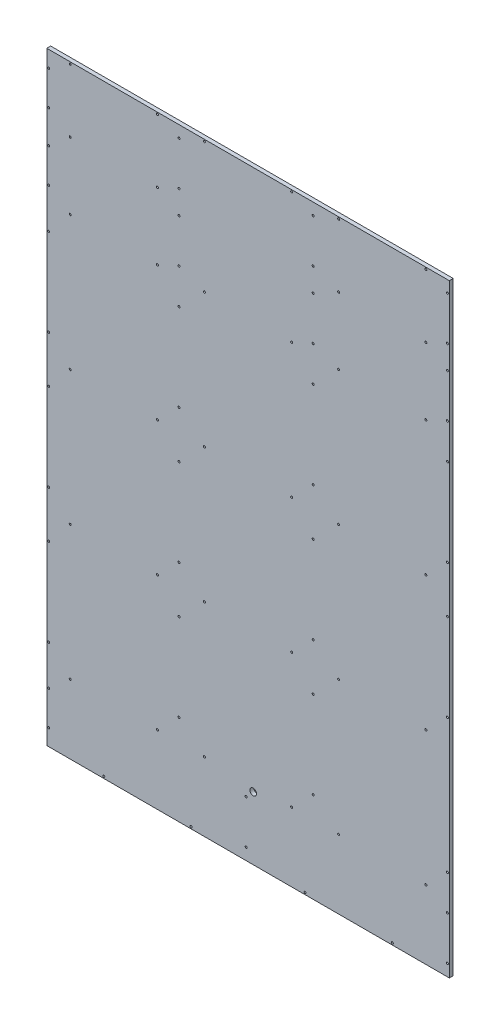
from build123d import *

# Parameters (mm, degrees)
SKETCH1_W           = 600
SKETCH1_H           = 900
SKETCH1_R           = 1.5
BOSS_EXTRUDE1_DEPTH = 5.8
SKETCH2_R           = 1.5
BOSS_EXTRUDE3_DEPTH = 5.8
SKETCH3_R           = 5
CUT_EXTRUDE1_DEPTH  = 10


with BuildPart() as part:
    # Sketch1 → Boss-Extrude1 (new body)
    with BuildSketch(Plane.XY):
        with Locations((300, 450)):
            Rectangle(SKETCH1_W, SKETCH1_H)
        with Locations((165, 102.9)):
            Circle(SKETCH1_R, mode=Mode.SUBTRACT)
        with Locations((35, 102.9)):
            Circle(SKETCH1_R, mode=Mode.SUBTRACT)
        with Locations((197.1, 265)):
            Circle(SKETCH1_R, mode=Mode.SUBTRACT)
        with Locations((197.1, 135)):
            Circle(SKETCH1_R, mode=Mode.SUBTRACT)
        with Locations((2.9, 135)):
            Circle(SKETCH1_R, mode=Mode.SUBTRACT)
        with Locations((2.9, 265)):
            Circle(SKETCH1_R, mode=Mode.SUBTRACT)
        with Locations((10.9, 265)):
            Circle(SKETCH1_R, mode=Mode.SUBTRACT)
        with Locations((10.9, 135)):
            Circle(SKETCH1_R, mode=Mode.SUBTRACT)
        with Locations((85, 2.9)):
            Circle(SKETCH1_R, mode=Mode.SUBTRACT)
        with Locations((215, 2.9)):
            Circle(SKETCH1_R, mode=Mode.SUBTRACT)
        with Locations((297.1, 82.5)):
            Circle(SKETCH1_R, mode=Mode.SUBTRACT)
        with Locations((297.1, 17.5)):
            Circle(SKETCH1_R, mode=Mode.SUBTRACT)
        with Locations((2.9, 24.5)):
            Circle(SKETCH1_R, mode=Mode.SUBTRACT)
        with Locations((2.9, 75.5)):
            Circle(SKETCH1_R, mode=Mode.SUBTRACT)
        with Locations((10.9, 75.5)):
            Circle(SKETCH1_R, mode=Mode.SUBTRACT)
        with Locations((10.9, 24.5)):
            Circle(SKETCH1_R, mode=Mode.SUBTRACT)
        with Locations((35, 702.9)):
            Circle(SKETCH1_R, mode=Mode.SUBTRACT)
        with Locations((165, 702.9)):
            Circle(SKETCH1_R, mode=Mode.SUBTRACT)
        with Locations((197.1, 782.5)):
            Circle(SKETCH1_R, mode=Mode.SUBTRACT)
        with Locations((197.1, 717.5)):
            Circle(SKETCH1_R, mode=Mode.SUBTRACT)
        with Locations((2.9, 775.5)):
            Circle(SKETCH1_R, mode=Mode.SUBTRACT)
        with Locations((10.9, 775.5)):
            Circle(SKETCH1_R, mode=Mode.SUBTRACT)
        with Locations((2.9, 724.5)):
            Circle(SKETCH1_R, mode=Mode.SUBTRACT)
        with Locations((10.9, 724.5)):
            Circle(SKETCH1_R, mode=Mode.SUBTRACT)
        with Locations((385, 2.9)):
            Circle(SKETCH1_R, mode=Mode.SUBTRACT)
        with Locations((515, 2.9)):
            Circle(SKETCH1_R, mode=Mode.SUBTRACT)
        with Locations((597.1, 82.5)):
            Circle(SKETCH1_R, mode=Mode.SUBTRACT)
        with Locations((597.1, 17.5)):
            Circle(SKETCH1_R, mode=Mode.SUBTRACT)
        with Locations((302.9, 24.5)):
            Circle(SKETCH1_R, mode=Mode.SUBTRACT)
        with Locations((302.9, 75.5)):
            Circle(SKETCH1_R, mode=Mode.SUBTRACT)
        with Locations((310.9, 75.5)):
            Circle(SKETCH1_R, mode=Mode.SUBTRACT)
        with Locations((310.9, 24.5)):
            Circle(SKETCH1_R, mode=Mode.SUBTRACT)
        with Locations((365, 102.9)):
            Circle(SKETCH1_R, mode=Mode.SUBTRACT)
        with Locations((235, 102.9)):
            Circle(SKETCH1_R, mode=Mode.SUBTRACT)
        with Locations((397.1, 265)):
            Circle(SKETCH1_R, mode=Mode.SUBTRACT)
        with Locations((397.1, 135)):
            Circle(SKETCH1_R, mode=Mode.SUBTRACT)
        with Locations((202.9, 135)):
            Circle(SKETCH1_R, mode=Mode.SUBTRACT)
        with Locations((202.9, 265)):
            Circle(SKETCH1_R, mode=Mode.SUBTRACT)
        with Locations((210.9, 265)):
            Circle(SKETCH1_R, mode=Mode.SUBTRACT)
        with Locations((210.9, 135)):
            Circle(SKETCH1_R, mode=Mode.SUBTRACT)
        with Locations((565, 102.9)):
            Circle(SKETCH1_R, mode=Mode.SUBTRACT)
        with Locations((435, 102.9)):
            Circle(SKETCH1_R, mode=Mode.SUBTRACT)
        with Locations((597.1, 265)):
            Circle(SKETCH1_R, mode=Mode.SUBTRACT)
        with Locations((597.1, 135)):
            Circle(SKETCH1_R, mode=Mode.SUBTRACT)
        with Locations((402.9, 135)):
            Circle(SKETCH1_R, mode=Mode.SUBTRACT)
        with Locations((402.9, 265)):
            Circle(SKETCH1_R, mode=Mode.SUBTRACT)
        with Locations((410.9, 265)):
            Circle(SKETCH1_R, mode=Mode.SUBTRACT)
        with Locations((410.9, 135)):
            Circle(SKETCH1_R, mode=Mode.SUBTRACT)
        with Locations((365, 302.9)):
            Circle(SKETCH1_R, mode=Mode.SUBTRACT)
        with Locations((235, 302.9)):
            Circle(SKETCH1_R, mode=Mode.SUBTRACT)
        with Locations((397.1, 465)):
            Circle(SKETCH1_R, mode=Mode.SUBTRACT)
        with Locations((397.1, 335)):
            Circle(SKETCH1_R, mode=Mode.SUBTRACT)
        with Locations((202.9, 335)):
            Circle(SKETCH1_R, mode=Mode.SUBTRACT)
        with Locations((202.9, 465)):
            Circle(SKETCH1_R, mode=Mode.SUBTRACT)
        with Locations((210.9, 465)):
            Circle(SKETCH1_R, mode=Mode.SUBTRACT)
        with Locations((210.9, 335)):
            Circle(SKETCH1_R, mode=Mode.SUBTRACT)
        with Locations((565, 302.9)):
            Circle(SKETCH1_R, mode=Mode.SUBTRACT)
        with Locations((435, 302.9)):
            Circle(SKETCH1_R, mode=Mode.SUBTRACT)
        with Locations((597.1, 465)):
            Circle(SKETCH1_R, mode=Mode.SUBTRACT)
        with Locations((597.1, 335)):
            Circle(SKETCH1_R, mode=Mode.SUBTRACT)
        with Locations((402.9, 335)):
            Circle(SKETCH1_R, mode=Mode.SUBTRACT)
        with Locations((402.9, 465)):
            Circle(SKETCH1_R, mode=Mode.SUBTRACT)
        with Locations((410.9, 465)):
            Circle(SKETCH1_R, mode=Mode.SUBTRACT)
        with Locations((410.9, 335)):
            Circle(SKETCH1_R, mode=Mode.SUBTRACT)
        with Locations((365, 502.9)):
            Circle(SKETCH1_R, mode=Mode.SUBTRACT)
        with Locations((235, 502.9)):
            Circle(SKETCH1_R, mode=Mode.SUBTRACT)
        with Locations((397.1, 665)):
            Circle(SKETCH1_R, mode=Mode.SUBTRACT)
        with Locations((397.1, 535)):
            Circle(SKETCH1_R, mode=Mode.SUBTRACT)
        with Locations((202.9, 535)):
            Circle(SKETCH1_R, mode=Mode.SUBTRACT)
        with Locations((202.9, 665)):
            Circle(SKETCH1_R, mode=Mode.SUBTRACT)
        with Locations((210.9, 665)):
            Circle(SKETCH1_R, mode=Mode.SUBTRACT)
        with Locations((210.9, 535)):
            Circle(SKETCH1_R, mode=Mode.SUBTRACT)
        with Locations((565, 502.9)):
            Circle(SKETCH1_R, mode=Mode.SUBTRACT)
        with Locations((435, 502.9)):
            Circle(SKETCH1_R, mode=Mode.SUBTRACT)
        with Locations((597.1, 665)):
            Circle(SKETCH1_R, mode=Mode.SUBTRACT)
        with Locations((597.1, 535)):
            Circle(SKETCH1_R, mode=Mode.SUBTRACT)
        with Locations((402.9, 535)):
            Circle(SKETCH1_R, mode=Mode.SUBTRACT)
        with Locations((402.9, 665)):
            Circle(SKETCH1_R, mode=Mode.SUBTRACT)
        with Locations((410.9, 665)):
            Circle(SKETCH1_R, mode=Mode.SUBTRACT)
        with Locations((410.9, 535)):
            Circle(SKETCH1_R, mode=Mode.SUBTRACT)
        with Locations((165, 302.9)):
            Circle(SKETCH1_R, mode=Mode.SUBTRACT)
        with Locations((35, 302.9)):
            Circle(SKETCH1_R, mode=Mode.SUBTRACT)
        with Locations((197.1, 465)):
            Circle(SKETCH1_R, mode=Mode.SUBTRACT)
        with Locations((197.1, 335)):
            Circle(SKETCH1_R, mode=Mode.SUBTRACT)
        with Locations((2.9, 335)):
            Circle(SKETCH1_R, mode=Mode.SUBTRACT)
        with Locations((2.9, 465)):
            Circle(SKETCH1_R, mode=Mode.SUBTRACT)
        with Locations((10.9, 465)):
            Circle(SKETCH1_R, mode=Mode.SUBTRACT)
        with Locations((10.9, 335)):
            Circle(SKETCH1_R, mode=Mode.SUBTRACT)
        with Locations((165, 502.9)):
            Circle(SKETCH1_R, mode=Mode.SUBTRACT)
        with Locations((35, 502.9)):
            Circle(SKETCH1_R, mode=Mode.SUBTRACT)
        with Locations((197.1, 665)):
            Circle(SKETCH1_R, mode=Mode.SUBTRACT)
        with Locations((197.1, 535)):
            Circle(SKETCH1_R, mode=Mode.SUBTRACT)
        with Locations((2.9, 535)):
            Circle(SKETCH1_R, mode=Mode.SUBTRACT)
        with Locations((2.9, 665)):
            Circle(SKETCH1_R, mode=Mode.SUBTRACT)
        with Locations((10.9, 665)):
            Circle(SKETCH1_R, mode=Mode.SUBTRACT)
        with Locations((10.9, 535)):
            Circle(SKETCH1_R, mode=Mode.SUBTRACT)
        with Locations((235, 702.9)):
            Circle(SKETCH1_R, mode=Mode.SUBTRACT)
        with Locations((365, 702.9)):
            Circle(SKETCH1_R, mode=Mode.SUBTRACT)
        with Locations((397.1, 782.5)):
            Circle(SKETCH1_R, mode=Mode.SUBTRACT)
        with Locations((397.1, 717.5)):
            Circle(SKETCH1_R, mode=Mode.SUBTRACT)
        with Locations((202.9, 775.5)):
            Circle(SKETCH1_R, mode=Mode.SUBTRACT)
        with Locations((210.9, 775.5)):
            Circle(SKETCH1_R, mode=Mode.SUBTRACT)
        with Locations((202.9, 724.5)):
            Circle(SKETCH1_R, mode=Mode.SUBTRACT)
        with Locations((210.9, 724.5)):
            Circle(SKETCH1_R, mode=Mode.SUBTRACT)
        with Locations((435, 702.9)):
            Circle(SKETCH1_R, mode=Mode.SUBTRACT)
        with Locations((565, 702.9)):
            Circle(SKETCH1_R, mode=Mode.SUBTRACT)
        with Locations((597.1, 782.5)):
            Circle(SKETCH1_R, mode=Mode.SUBTRACT)
        with Locations((597.1, 717.5)):
            Circle(SKETCH1_R, mode=Mode.SUBTRACT)
        with Locations((402.9, 775.5)):
            Circle(SKETCH1_R, mode=Mode.SUBTRACT)
        with Locations((410.9, 775.5)):
            Circle(SKETCH1_R, mode=Mode.SUBTRACT)
        with Locations((402.9, 724.5)):
            Circle(SKETCH1_R, mode=Mode.SUBTRACT)
        with Locations((410.9, 724.5)):
            Circle(SKETCH1_R, mode=Mode.SUBTRACT)
        with Locations((435, 802.9)):
            Circle(SKETCH1_R, mode=Mode.SUBTRACT)
        with Locations((565, 802.9)):
            Circle(SKETCH1_R, mode=Mode.SUBTRACT)
        with Locations((597.1, 882.5)):
            Circle(SKETCH1_R, mode=Mode.SUBTRACT)
        with Locations((597.1, 817.5)):
            Circle(SKETCH1_R, mode=Mode.SUBTRACT)
        with Locations((402.9, 875.5)):
            Circle(SKETCH1_R, mode=Mode.SUBTRACT)
        with Locations((410.9, 875.5)):
            Circle(SKETCH1_R, mode=Mode.SUBTRACT)
        with Locations((402.9, 824.5)):
            Circle(SKETCH1_R, mode=Mode.SUBTRACT)
        with Locations((410.9, 824.5)):
            Circle(SKETCH1_R, mode=Mode.SUBTRACT)
        with Locations((35, 802.9)):
            Circle(SKETCH1_R, mode=Mode.SUBTRACT)
        with Locations((165, 802.9)):
            Circle(SKETCH1_R, mode=Mode.SUBTRACT)
        with Locations((197.1, 882.5)):
            Circle(SKETCH1_R, mode=Mode.SUBTRACT)
        with Locations((197.1, 817.5)):
            Circle(SKETCH1_R, mode=Mode.SUBTRACT)
        with Locations((2.9, 875.5)):
            Circle(SKETCH1_R, mode=Mode.SUBTRACT)
        with Locations((10.9, 875.5)):
            Circle(SKETCH1_R, mode=Mode.SUBTRACT)
        with Locations((2.9, 824.5)):
            Circle(SKETCH1_R, mode=Mode.SUBTRACT)
        with Locations((10.9, 824.5)):
            Circle(SKETCH1_R, mode=Mode.SUBTRACT)
        with Locations((397.1, 817.5)):
            Circle(SKETCH1_R, mode=Mode.SUBTRACT)
        with Locations((397.1, 882.5)):
            Circle(SKETCH1_R, mode=Mode.SUBTRACT)
        with Locations((165, 897.1)):
            Circle(SKETCH1_R, mode=Mode.SUBTRACT)
        with Locations((35, 897.1)):
            Circle(SKETCH1_R, mode=Mode.SUBTRACT)
        with Locations((235, 897.1)):
            Circle(SKETCH1_R, mode=Mode.SUBTRACT)
        with Locations((365, 897.1)):
            Circle(SKETCH1_R, mode=Mode.SUBTRACT)
        with Locations((435, 897.1)):
            Circle(SKETCH1_R, mode=Mode.SUBTRACT)
        with Locations((565, 897.1)):
            Circle(SKETCH1_R, mode=Mode.SUBTRACT)
        with BuildLine():
            Line((594.2, 15.8), (594.2, 84.2))
            ThreePointArc((594.2, 84.2), (591.271067812, 91.271067812), (584.2, 94.2))
            Line((584.2, 94.2), (329.2, 94.2))
            ThreePointArc((329.2, 94.2), (322.128932188, 91.271067812), (319.2, 84.2))
            Line((319.2, 84.2), (319.2, 15.8))
            ThreePointArc((319.2, 15.8), (322.128932188, 8.728932188), (329.2, 5.8))
            Line((329.2, 5.8), (584.2, 5.8))
            ThreePointArc((584.2, 5.8), (591.271067812, 8.728932188), (594.2, 15.8))
        make_face(mode=Mode.SUBTRACT)
        with BuildLine():
            Line((194.2, 115.8), (194.2, 284.2))
            ThreePointArc((194.2, 284.2), (191.271067812, 291.271067812), (184.2, 294.2))
            Line((184.2, 294.2), (29.2, 294.2))
            ThreePointArc((29.2, 294.2), (22.128932188, 291.271067812), (19.2, 284.2))
            Line((19.2, 284.2), (19.2, 115.8))
            ThreePointArc((19.2, 115.8), (22.128932188, 108.728932188), (29.2, 105.8))
            Line((29.2, 105.8), (184.2, 105.8))
            ThreePointArc((184.2, 105.8), (191.271067812, 108.728932188), (194.2, 115.8))
        make_face(mode=Mode.SUBTRACT)
        with BuildLine():
            Line((394.2, 115.8), (394.2, 284.2))
            ThreePointArc((394.2, 284.2), (391.271067812, 291.271067812), (384.2, 294.2))
            Line((384.2, 294.2), (229.2, 294.2))
            ThreePointArc((229.2, 294.2), (222.128932188, 291.271067812), (219.2, 284.2))
            Line((219.2, 284.2), (219.2, 115.8))
            ThreePointArc((219.2, 115.8), (222.128932188, 108.728932188), (229.2, 105.8))
            Line((229.2, 105.8), (384.2, 105.8))
            ThreePointArc((384.2, 105.8), (391.271067812, 108.728932188), (394.2, 115.8))
        make_face(mode=Mode.SUBTRACT)
        with BuildLine():
            Line((594.2, 115.8), (594.2, 284.2))
            ThreePointArc((594.2, 284.2), (591.271067812, 291.271067812), (584.2, 294.2))
            Line((584.2, 294.2), (429.2, 294.2))
            ThreePointArc((429.2, 294.2), (422.128932188, 291.271067812), (419.2, 284.2))
            Line((419.2, 284.2), (419.2, 115.8))
            ThreePointArc((419.2, 115.8), (422.128932188, 108.728932188), (429.2, 105.8))
            Line((429.2, 105.8), (584.2, 105.8))
            ThreePointArc((584.2, 105.8), (591.271067812, 108.728932188), (594.2, 115.8))
        make_face(mode=Mode.SUBTRACT)
        with BuildLine():
            Line((394.2, 315.8), (394.2, 484.2))
            ThreePointArc((394.2, 484.2), (391.271067812, 491.271067812), (384.2, 494.2))
            Line((384.2, 494.2), (229.2, 494.2))
            ThreePointArc((229.2, 494.2), (222.128932188, 491.271067812), (219.2, 484.2))
            Line((219.2, 484.2), (219.2, 315.8))
            ThreePointArc((219.2, 315.8), (222.128932188, 308.728932188), (229.2, 305.8))
            Line((229.2, 305.8), (384.2, 305.8))
            ThreePointArc((384.2, 305.8), (391.271067812, 308.728932188), (394.2, 315.8))
        make_face(mode=Mode.SUBTRACT)
        with BuildLine():
            Line((594.2, 315.8), (594.2, 484.2))
            ThreePointArc((594.2, 484.2), (591.271067812, 491.271067812), (584.2, 494.2))
            Line((584.2, 494.2), (429.2, 494.2))
            ThreePointArc((429.2, 494.2), (422.128932188, 491.271067812), (419.2, 484.2))
            Line((419.2, 484.2), (419.2, 315.8))
            ThreePointArc((419.2, 315.8), (422.128932188, 308.728932188), (429.2, 305.8))
            Line((429.2, 305.8), (584.2, 305.8))
            ThreePointArc((584.2, 305.8), (591.271067812, 308.728932188), (594.2, 315.8))
        make_face(mode=Mode.SUBTRACT)
        with BuildLine():
            Line((394.2, 515.8), (394.2, 684.2))
            ThreePointArc((394.2, 684.2), (391.271067812, 691.271067812), (384.2, 694.2))
            Line((384.2, 694.2), (229.2, 694.2))
            ThreePointArc((229.2, 694.2), (222.128932188, 691.271067812), (219.2, 684.2))
            Line((219.2, 684.2), (219.2, 515.8))
            ThreePointArc((219.2, 515.8), (222.128932188, 508.728932188), (229.2, 505.8))
            Line((229.2, 505.8), (384.2, 505.8))
            ThreePointArc((384.2, 505.8), (391.271067812, 508.728932188), (394.2, 515.8))
        make_face(mode=Mode.SUBTRACT)
        with BuildLine():
            Line((294.2, 15.8), (294.2, 84.2))
            ThreePointArc((294.2, 84.2), (291.271067812, 91.271067812), (284.2, 94.2))
            Line((284.2, 94.2), (29.2, 94.2))
            ThreePointArc((29.2, 94.2), (22.128932188, 91.271067812), (19.2, 84.2))
            Line((19.2, 84.2), (19.2, 15.8))
            ThreePointArc((19.2, 15.8), (22.128932188, 8.728932188), (29.2, 5.8))
            Line((29.2, 5.8), (284.2, 5.8))
            ThreePointArc((284.2, 5.8), (291.271067812, 8.728932188), (294.2, 15.8))
        make_face(mode=Mode.SUBTRACT)
        with BuildLine():
            Line((594.2, 515.8), (594.2, 684.2))
            ThreePointArc((594.2, 684.2), (591.271067812, 691.271067812), (584.2, 694.2))
            Line((584.2, 694.2), (429.2, 694.2))
            ThreePointArc((429.2, 694.2), (422.128932188, 691.271067812), (419.2, 684.2))
            Line((419.2, 684.2), (419.2, 515.8))
            ThreePointArc((419.2, 515.8), (422.128932188, 508.728932188), (429.2, 505.8))
            Line((429.2, 505.8), (584.2, 505.8))
            ThreePointArc((584.2, 505.8), (591.271067812, 508.728932188), (594.2, 515.8))
        make_face(mode=Mode.SUBTRACT)
        with BuildLine():
            Line((194.2, 715.8), (194.2, 784.2))
            ThreePointArc((194.2, 784.2), (191.271067812, 791.271067812), (184.2, 794.2))
            Line((184.2, 794.2), (29.2, 794.2))
            ThreePointArc((29.2, 794.2), (22.128932188, 791.271067812), (19.2, 784.2))
            Line((19.2, 784.2), (19.2, 715.8))
            ThreePointArc((19.2, 715.8), (22.128932188, 708.728932188), (29.2, 705.8))
            Line((29.2, 705.8), (184.2, 705.8))
            ThreePointArc((184.2, 705.8), (191.271067812, 708.728932188), (194.2, 715.8))
        make_face(mode=Mode.SUBTRACT)
        with BuildLine():
            Line((194.2, 315.8), (194.2, 484.2))
            ThreePointArc((194.2, 484.2), (191.271067812, 491.271067812), (184.2, 494.2))
            Line((184.2, 494.2), (29.2, 494.2))
            ThreePointArc((29.2, 494.2), (22.128932188, 491.271067812), (19.2, 484.2))
            Line((19.2, 484.2), (19.2, 315.8))
            ThreePointArc((19.2, 315.8), (22.128932188, 308.728932188), (29.2, 305.8))
            Line((29.2, 305.8), (184.2, 305.8))
            ThreePointArc((184.2, 305.8), (191.271067812, 308.728932188), (194.2, 315.8))
        make_face(mode=Mode.SUBTRACT)
        with BuildLine():
            Line((194.2, 515.8), (194.2, 684.2))
            ThreePointArc((194.2, 684.2), (191.271067812, 691.271067812), (184.2, 694.2))
            Line((184.2, 694.2), (29.2, 694.2))
            ThreePointArc((29.2, 694.2), (22.128932188, 691.271067812), (19.2, 684.2))
            Line((19.2, 684.2), (19.2, 515.8))
            ThreePointArc((19.2, 515.8), (22.128932188, 508.728932188), (29.2, 505.8))
            Line((29.2, 505.8), (184.2, 505.8))
            ThreePointArc((184.2, 505.8), (191.271067812, 508.728932188), (194.2, 515.8))
        make_face(mode=Mode.SUBTRACT)
        with BuildLine():
            Line((394.2, 715.8), (394.2, 784.2))
            ThreePointArc((394.2, 784.2), (391.271067812, 791.271067812), (384.2, 794.2))
            Line((384.2, 794.2), (229.2, 794.2))
            ThreePointArc((229.2, 794.2), (222.128932188, 791.271067812), (219.2, 784.2))
            Line((219.2, 784.2), (219.2, 715.8))
            ThreePointArc((219.2, 715.8), (222.128932188, 708.728932188), (229.2, 705.8))
            Line((229.2, 705.8), (384.2, 705.8))
            ThreePointArc((384.2, 705.8), (391.271067812, 708.728932188), (394.2, 715.8))
        make_face(mode=Mode.SUBTRACT)
        with BuildLine():
            Line((594.2, 715.8), (594.2, 784.2))
            ThreePointArc((594.2, 784.2), (591.271067812, 791.271067812), (584.2, 794.2))
            Line((584.2, 794.2), (429.2, 794.2))
            ThreePointArc((429.2, 794.2), (422.128932188, 791.271067812), (419.2, 784.2))
            Line((419.2, 784.2), (419.2, 715.8))
            ThreePointArc((419.2, 715.8), (422.128932188, 708.728932188), (429.2, 705.8))
            Line((429.2, 705.8), (584.2, 705.8))
            ThreePointArc((584.2, 705.8), (591.271067812, 708.728932188), (594.2, 715.8))
        make_face(mode=Mode.SUBTRACT)
        with BuildLine():
            Line((594.2, 815.8), (594.2, 884.2))
            ThreePointArc((594.2, 884.2), (591.271067812, 891.271067812), (584.2, 894.2))
            Line((584.2, 894.2), (429.2, 894.2))
            ThreePointArc((429.2, 894.2), (422.128932188, 891.271067812), (419.2, 884.2))
            Line((419.2, 884.2), (419.2, 815.8))
            ThreePointArc((419.2, 815.8), (422.128932188, 808.728932188), (429.2, 805.8))
            Line((429.2, 805.8), (584.2, 805.8))
            ThreePointArc((584.2, 805.8), (591.271067812, 808.728932188), (594.2, 815.8))
        make_face(mode=Mode.SUBTRACT)
        with BuildLine():
            Line((194.2, 815.8), (194.2, 884.2))
            ThreePointArc((194.2, 884.2), (191.271067812, 891.271067812), (184.2, 894.2))
            Line((184.2, 894.2), (29.2, 894.2))
            ThreePointArc((29.2, 894.2), (22.128932188, 891.271067812), (19.2, 884.2))
            Line((19.2, 884.2), (19.2, 815.8))
            ThreePointArc((19.2, 815.8), (22.128932188, 808.728932188), (29.2, 805.8))
            Line((29.2, 805.8), (184.2, 805.8))
            ThreePointArc((184.2, 805.8), (191.271067812, 808.728932188), (194.2, 815.8))
        make_face(mode=Mode.SUBTRACT)
    extrude(amount=BOSS_EXTRUDE1_DEPTH)

    # Sketch2 → Boss-Extrude3 (add)
    with BuildSketch(Plane(origin=(0, 0, 5.8), x_dir=(-1, 0, 0), z_dir=(0, 0, -1))):
        with Locations((-202.9, 335)):
            Circle(SKETCH2_R)
        with Locations((-210.9, 265)):
            Circle(SKETCH2_R)
        with Locations((-210.9, 135)):
            Circle(SKETCH2_R)
        with Locations((-410.9, 135)):
            Circle(SKETCH2_R)
        with Locations((-410.9, 265)):
            Circle(SKETCH2_R)
        with Locations((-410.9, 335)):
            Circle(SKETCH2_R)
        with Locations((-410.9, 465)):
            Circle(SKETCH2_R)
        with Locations((-410.9, 535)):
            Circle(SKETCH2_R)
        with Locations((-410.9, 665)):
            Circle(SKETCH2_R)
        with Locations((-402.9, 535)):
            Circle(SKETCH2_R)
        with Locations((-402.9, 465)):
            Circle(SKETCH2_R)
        with Locations((-402.9, 335)):
            Circle(SKETCH2_R)
        with Locations((-402.9, 265)):
            Circle(SKETCH2_R)
        with Locations((-202.9, 265)):
            Circle(SKETCH2_R)
        with Locations((-202.9, 135)):
            Circle(SKETCH2_R)
        with Locations((-402.9, 875.5)):
            Circle(SKETCH2_R)
        with Locations((-402.9, 775.5)):
            Circle(SKETCH2_R)
        with Locations((-202.9, 775.5)):
            Circle(SKETCH2_R)
        with Locations((-402.9, 665)):
            Circle(SKETCH2_R)
        with Locations((-202.9, 665)):
            Circle(SKETCH2_R)
        with Locations((-202.9, 535)):
            Circle(SKETCH2_R)
        with Locations((-202.9, 465)):
            Circle(SKETCH2_R)
        with Locations((-402.9, 135)):
            Circle(SKETCH2_R)
        with Locations((-302.9, 75.5)):
            Circle(SKETCH2_R)
        with Locations((-302.9, 24.5)):
            Circle(SKETCH2_R)
        with Locations((-10.9, 265)):
            Circle(SKETCH2_R)
        with Locations((-10.9, 135)):
            Circle(SKETCH2_R)
        with Locations((-10.9, 75.5)):
            Circle(SKETCH2_R)
        with Locations((-10.9, 24.5)):
            Circle(SKETCH2_R)
        with Locations((-10.9, 775.5)):
            Circle(SKETCH2_R)
        with Locations((-10.9, 724.5)):
            Circle(SKETCH2_R)
        with Locations((-310.9, 75.5)):
            Circle(SKETCH2_R)
        with Locations((-310.9, 24.5)):
            Circle(SKETCH2_R)
        with Locations((-597.1, 265)):
            Circle(SKETCH2_R)
        with Locations((-210.9, 465)):
            Circle(SKETCH2_R)
        with Locations((-210.9, 335)):
            Circle(SKETCH2_R)
        with Locations((-210.9, 665)):
            Circle(SKETCH2_R)
        with Locations((-210.9, 535)):
            Circle(SKETCH2_R)
        with Locations((-10.9, 465)):
            Circle(SKETCH2_R)
        with Locations((-10.9, 335)):
            Circle(SKETCH2_R)
        with Locations((-10.9, 665)):
            Circle(SKETCH2_R)
        with Locations((-10.9, 535)):
            Circle(SKETCH2_R)
        with Locations((-210.9, 775.5)):
            Circle(SKETCH2_R)
        with Locations((-202.9, 724.5)):
            Circle(SKETCH2_R)
        with Locations((-210.9, 724.5)):
            Circle(SKETCH2_R)
        with Locations((-410.9, 775.5)):
            Circle(SKETCH2_R)
        with Locations((-402.9, 724.5)):
            Circle(SKETCH2_R)
        with Locations((-410.9, 724.5)):
            Circle(SKETCH2_R)
        with Locations((-410.9, 875.5)):
            Circle(SKETCH2_R)
        with Locations((-402.9, 824.5)):
            Circle(SKETCH2_R)
        with Locations((-410.9, 824.5)):
            Circle(SKETCH2_R)
        with Locations((-10.9, 875.5)):
            Circle(SKETCH2_R)
        with Locations((-10.9, 824.5)):
            Circle(SKETCH2_R)
        with BuildLine():
            Line((-29.2, 894.2), (-184.2, 894.2))
            ThreePointArc((-184.2, 894.2), (-191.271067812, 891.271067812), (-194.2, 884.2))
            Line((-194.2, 884.2), (-194.2, 815.8))
            ThreePointArc((-194.2, 815.8), (-191.271067812, 808.728932188), (-184.2, 805.8))
            Line((-184.2, 805.8), (-29.2, 805.8))
            ThreePointArc((-29.2, 805.8), (-22.128932188, 808.728932188), (-19.2, 815.8))
            Line((-19.2, 815.8), (-19.2, 884.2))
            ThreePointArc((-19.2, 884.2), (-22.128932188, 891.271067812), (-29.2, 894.2))
        make_face()
        with BuildLine():
            Line((-429.2, 894.2), (-584.2, 894.2))
            ThreePointArc((-584.2, 894.2), (-591.271067812, 891.271067812), (-594.2, 884.2))
            Line((-594.2, 884.2), (-594.2, 815.8))
            ThreePointArc((-594.2, 815.8), (-591.271067812, 808.728932188), (-584.2, 805.8))
            Line((-584.2, 805.8), (-429.2, 805.8))
            ThreePointArc((-429.2, 805.8), (-422.128932188, 808.728932188), (-419.2, 815.8))
            Line((-419.2, 815.8), (-419.2, 884.2))
            ThreePointArc((-419.2, 884.2), (-422.128932188, 891.271067812), (-429.2, 894.2))
        make_face()
        with BuildLine():
            Line((-429.2, 794.2), (-584.2, 794.2))
            ThreePointArc((-584.2, 794.2), (-591.271067812, 791.271067812), (-594.2, 784.2))
            Line((-594.2, 784.2), (-594.2, 715.8))
            ThreePointArc((-594.2, 715.8), (-591.271067812, 708.728932188), (-584.2, 705.8))
            Line((-584.2, 705.8), (-429.2, 705.8))
            ThreePointArc((-429.2, 705.8), (-422.128932188, 708.728932188), (-419.2, 715.8))
            Line((-419.2, 715.8), (-419.2, 784.2))
            ThreePointArc((-419.2, 784.2), (-422.128932188, 791.271067812), (-429.2, 794.2))
        make_face()
        with BuildLine():
            Line((-229.2, 794.2), (-384.2, 794.2))
            ThreePointArc((-384.2, 794.2), (-391.271067812, 791.271067812), (-394.2, 784.2))
            Line((-394.2, 784.2), (-394.2, 715.8))
            ThreePointArc((-394.2, 715.8), (-391.271067812, 708.728932188), (-384.2, 705.8))
            Line((-384.2, 705.8), (-229.2, 705.8))
            ThreePointArc((-229.2, 705.8), (-222.128932188, 708.728932188), (-219.2, 715.8))
            Line((-219.2, 715.8), (-219.2, 784.2))
            ThreePointArc((-219.2, 784.2), (-222.128932188, 791.271067812), (-229.2, 794.2))
        make_face()
        with BuildLine():
            Line((-194.2, 684.2), (-194.2, 515.8))
            ThreePointArc((-194.2, 515.8), (-191.271067812, 508.728932188), (-184.2, 505.8))
            Line((-184.2, 505.8), (-29.2, 505.8))
            ThreePointArc((-29.2, 505.8), (-22.128932188, 508.728932188), (-19.2, 515.8))
            Line((-19.2, 515.8), (-19.2, 684.2))
            ThreePointArc((-19.2, 684.2), (-22.128932188, 691.271067812), (-29.2, 694.2))
            Line((-29.2, 694.2), (-184.2, 694.2))
            ThreePointArc((-184.2, 694.2), (-191.271067812, 691.271067812), (-194.2, 684.2))
        make_face()
        with BuildLine():
            Line((-194.2, 484.2), (-194.2, 315.8))
            ThreePointArc((-194.2, 315.8), (-191.271067812, 308.728932188), (-184.2, 305.8))
            Line((-184.2, 305.8), (-29.2, 305.8))
            ThreePointArc((-29.2, 305.8), (-22.128932188, 308.728932188), (-19.2, 315.8))
            Line((-19.2, 315.8), (-19.2, 484.2))
            ThreePointArc((-19.2, 484.2), (-22.128932188, 491.271067812), (-29.2, 494.2))
            Line((-29.2, 494.2), (-184.2, 494.2))
            ThreePointArc((-184.2, 494.2), (-191.271067812, 491.271067812), (-194.2, 484.2))
        make_face()
        with BuildLine():
            Line((-594.2, 684.2), (-594.2, 515.8))
            ThreePointArc((-594.2, 515.8), (-591.271067812, 508.728932188), (-584.2, 505.8))
            Line((-584.2, 505.8), (-429.2, 505.8))
            ThreePointArc((-429.2, 505.8), (-422.128932188, 508.728932188), (-419.2, 515.8))
            Line((-419.2, 515.8), (-419.2, 684.2))
            ThreePointArc((-419.2, 684.2), (-422.128932188, 691.271067812), (-429.2, 694.2))
            Line((-429.2, 694.2), (-584.2, 694.2))
            ThreePointArc((-584.2, 694.2), (-591.271067812, 691.271067812), (-594.2, 684.2))
        make_face()
        with BuildLine():
            Line((-394.2, 684.2), (-394.2, 515.8))
            ThreePointArc((-394.2, 515.8), (-391.271067812, 508.728932188), (-384.2, 505.8))
            Line((-384.2, 505.8), (-229.2, 505.8))
            ThreePointArc((-229.2, 505.8), (-222.128932188, 508.728932188), (-219.2, 515.8))
            Line((-219.2, 515.8), (-219.2, 684.2))
            ThreePointArc((-219.2, 684.2), (-222.128932188, 691.271067812), (-229.2, 694.2))
            Line((-229.2, 694.2), (-384.2, 694.2))
            ThreePointArc((-384.2, 694.2), (-391.271067812, 691.271067812), (-394.2, 684.2))
        make_face()
        with BuildLine():
            Line((-594.2, 484.2), (-594.2, 315.8))
            ThreePointArc((-594.2, 315.8), (-591.271067812, 308.728932188), (-584.2, 305.8))
            Line((-584.2, 305.8), (-429.2, 305.8))
            ThreePointArc((-429.2, 305.8), (-422.128932188, 308.728932188), (-419.2, 315.8))
            Line((-419.2, 315.8), (-419.2, 484.2))
            ThreePointArc((-419.2, 484.2), (-422.128932188, 491.271067812), (-429.2, 494.2))
            Line((-429.2, 494.2), (-584.2, 494.2))
            ThreePointArc((-584.2, 494.2), (-591.271067812, 491.271067812), (-594.2, 484.2))
        make_face()
        with BuildLine():
            Line((-394.2, 484.2), (-394.2, 315.8))
            ThreePointArc((-394.2, 315.8), (-391.271067812, 308.728932188), (-384.2, 305.8))
            Line((-384.2, 305.8), (-229.2, 305.8))
            ThreePointArc((-229.2, 305.8), (-222.128932188, 308.728932188), (-219.2, 315.8))
            Line((-219.2, 315.8), (-219.2, 484.2))
            ThreePointArc((-219.2, 484.2), (-222.128932188, 491.271067812), (-229.2, 494.2))
            Line((-229.2, 494.2), (-384.2, 494.2))
            ThreePointArc((-384.2, 494.2), (-391.271067812, 491.271067812), (-394.2, 484.2))
        make_face()
        with BuildLine():
            Line((-594.2, 284.2), (-594.2, 115.8))
            ThreePointArc((-594.2, 115.8), (-591.271067812, 108.728932188), (-584.2, 105.8))
            Line((-584.2, 105.8), (-429.2, 105.8))
            ThreePointArc((-429.2, 105.8), (-422.128932188, 108.728932188), (-419.2, 115.8))
            Line((-419.2, 115.8), (-419.2, 284.2))
            ThreePointArc((-419.2, 284.2), (-422.128932188, 291.271067812), (-429.2, 294.2))
            Line((-429.2, 294.2), (-584.2, 294.2))
            ThreePointArc((-584.2, 294.2), (-591.271067812, 291.271067812), (-594.2, 284.2))
        make_face()
        with BuildLine():
            Line((-394.2, 284.2), (-394.2, 115.8))
            ThreePointArc((-394.2, 115.8), (-391.271067812, 108.728932188), (-384.2, 105.8))
            Line((-384.2, 105.8), (-229.2, 105.8))
            ThreePointArc((-229.2, 105.8), (-222.128932188, 108.728932188), (-219.2, 115.8))
            Line((-219.2, 115.8), (-219.2, 284.2))
            ThreePointArc((-219.2, 284.2), (-222.128932188, 291.271067812), (-229.2, 294.2))
            Line((-229.2, 294.2), (-384.2, 294.2))
            ThreePointArc((-384.2, 294.2), (-391.271067812, 291.271067812), (-394.2, 284.2))
        make_face()
        with BuildLine():
            Line((-594.2, 84.2), (-594.2, 15.8))
            ThreePointArc((-594.2, 15.8), (-591.271067812, 8.728932188), (-584.2, 5.8))
            Line((-584.2, 5.8), (-329.2, 5.8))
            ThreePointArc((-329.2, 5.8), (-322.128932188, 8.728932188), (-319.2, 15.8))
            Line((-319.2, 15.8), (-319.2, 84.2))
            ThreePointArc((-319.2, 84.2), (-322.128932188, 91.271067812), (-329.2, 94.2))
            Line((-329.2, 94.2), (-584.2, 94.2))
            ThreePointArc((-584.2, 94.2), (-591.271067812, 91.271067812), (-594.2, 84.2))
        make_face()
        with BuildLine():
            Line((-29.2, 794.2), (-184.2, 794.2))
            ThreePointArc((-184.2, 794.2), (-191.271067812, 791.271067812), (-194.2, 784.2))
            Line((-194.2, 784.2), (-194.2, 715.8))
            ThreePointArc((-194.2, 715.8), (-191.271067812, 708.728932188), (-184.2, 705.8))
            Line((-184.2, 705.8), (-29.2, 705.8))
            ThreePointArc((-29.2, 705.8), (-22.128932188, 708.728932188), (-19.2, 715.8))
            Line((-19.2, 715.8), (-19.2, 784.2))
            ThreePointArc((-19.2, 784.2), (-22.128932188, 791.271067812), (-29.2, 794.2))
        make_face()
        with BuildLine():
            Line((-294.2, 84.2), (-294.2, 15.8))
            ThreePointArc((-294.2, 15.8), (-291.271067812, 8.728932188), (-284.2, 5.8))
            Line((-284.2, 5.8), (-29.2, 5.8))
            ThreePointArc((-29.2, 5.8), (-22.128932188, 8.728932188), (-19.2, 15.8))
            Line((-19.2, 15.8), (-19.2, 84.2))
            ThreePointArc((-19.2, 84.2), (-22.128932188, 91.271067812), (-29.2, 94.2))
            Line((-29.2, 94.2), (-284.2, 94.2))
            ThreePointArc((-284.2, 94.2), (-291.271067812, 91.271067812), (-294.2, 84.2))
        make_face()
        with BuildLine():
            Line((-194.2, 284.2), (-194.2, 115.8))
            ThreePointArc((-194.2, 115.8), (-191.271067812, 108.728932188), (-184.2, 105.8))
            Line((-184.2, 105.8), (-29.2, 105.8))
            ThreePointArc((-29.2, 105.8), (-22.128932188, 108.728932188), (-19.2, 115.8))
            Line((-19.2, 115.8), (-19.2, 284.2))
            ThreePointArc((-19.2, 284.2), (-22.128932188, 291.271067812), (-29.2, 294.2))
            Line((-29.2, 294.2), (-184.2, 294.2))
            ThreePointArc((-184.2, 294.2), (-191.271067812, 291.271067812), (-194.2, 284.2))
        make_face()
    extrude(amount=BOSS_EXTRUDE3_DEPTH)

    # Sketch3 → Cut-Extrude1 (cut)
    with BuildSketch(Plane.XY.offset(5.8)):
        with Locations((307.6, 94)):
            Circle(SKETCH3_R)
    extrude(amount=-CUT_EXTRUDE1_DEPTH, mode=Mode.SUBTRACT)


solid = part.part
